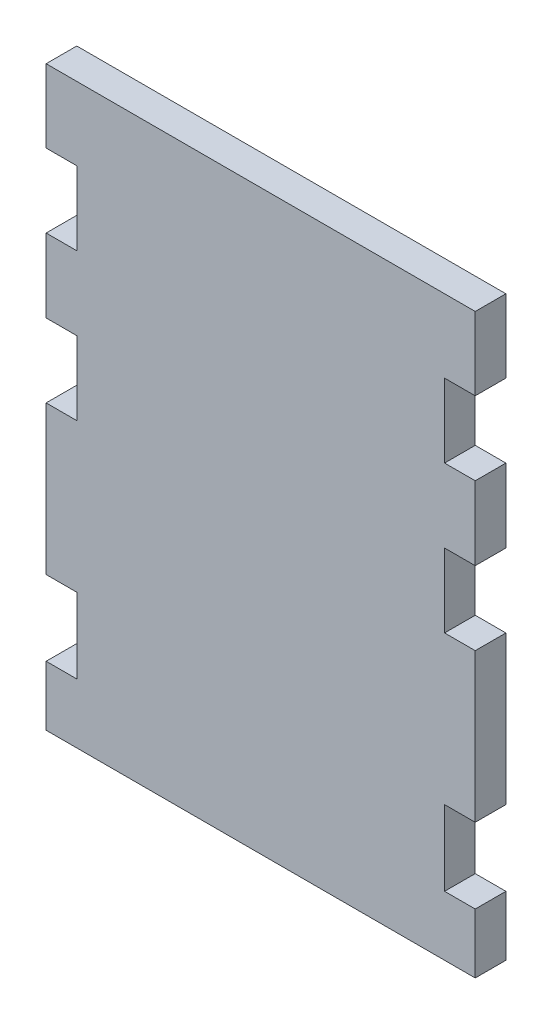
from build123d import *

# Parameters (mm, degrees)
SKETCH1_W           = 42
SKETCH1_H           = 58
BOSS_EXTRUDE1_DEPTH = 3
SKETCH2_W           = 3
SKETCH2_H           = 7.199999996
SKETCH2_H_2         = 7.35
CUT_EXTRUDE1_DEPTH  = 3
SKETCH3_W           = 42
SKETCH3_H           = 1.5
CUT_EXTRUDE2_DEPTH  = 4


with BuildPart() as part:
    # Sketch1 → Boss-Extrude1 (new body)
    with BuildSketch(Plane.XY):
        with Locations((21, 29)):
            Rectangle(SKETCH1_W, SKETCH1_H)
    extrude(amount=BOSS_EXTRUDE1_DEPTH)

    # Sketch2 → Cut-Extrude1 (cut)
    with BuildSketch(Plane.XY.offset(3)):
        with Locations((40.5, 47.24818585)):
            Rectangle(SKETCH2_W, SKETCH2_H)
        with Locations((40.5, 32.848185857)):
            Rectangle(SKETCH2_W, SKETCH2_H)
        with Locations((1.5, 47.24818585)):
            Rectangle(SKETCH2_W, SKETCH2_H)
        with Locations((1.5, 32.848185857)):
            Rectangle(SKETCH2_W, SKETCH2_H)
        with Locations((1.5, 11.023185866)):
            Rectangle(SKETCH2_W, SKETCH2_H_2)
        with Locations((40.5, 11.023185866)):
            Rectangle(SKETCH2_W, SKETCH2_H_2)
    extrude(amount=-CUT_EXTRUDE1_DEPTH, mode=Mode.SUBTRACT)

    # Sketch3 → Cut-Extrude2 (cut, through all)
    with BuildSketch(Plane.XY.offset(3)):
        with Locations((21, 0.75)):
            Rectangle(SKETCH3_W, SKETCH3_H)
    extrude(amount=-CUT_EXTRUDE2_DEPTH, mode=Mode.SUBTRACT)


solid = part.part
